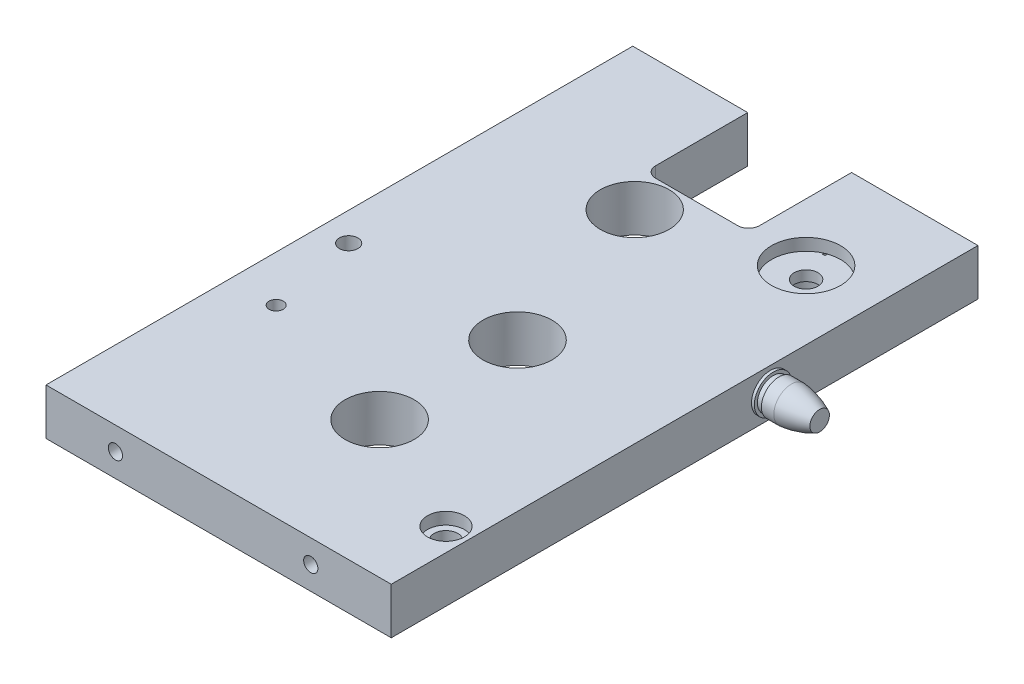
from build123d import *

# Parameters (mm, degrees)
SKETCH1_W           = 95.25
SKETCH1_H           = 12.8
BOSS_EXTRUDE1_DEPTH = 161.88
SKETCH1_3_R         = 3.1
CUT_EXTRUDE1_DEPTH  = 20.2
SKETCH1_4_R         = 2.395
CUT_EXTRUDE2_DEPTH  = 21.5
CUT_EXTRUDE3_REACH  = 369.677
SKETCH2_R           = 9.525
CUT_EXTRUDE4_REACH  = 369.677
SKETCH3_R           = 3.265
SKETCH3_R_2         = 1.96
SKETCH3_R_3         = 2.56
SKETCH4_R           = 9.525
SKETCH4_R_2         = 5.09
CUT_EXTRUDE5_DEPTH  = 3.32
SKETCH5_R           = 5.31
CUT_EXTRUDE6_DEPTH  = 6.65
SKETCH6_R           = 1.965
CUT_EXTRUDE7_DEPTH  = 17.25
SKETCH7_R           = 1.97
CUT_EXTRUDE8_DEPTH  = 15.87
SKETCH9_R           = 9.5
CUT_EXTRUDE9_DEPTH  = 368.677154617


with BuildPart() as part:
    # Sketch1 → Boss-Extrude1 (new body)
    with BuildSketch(Plane.XY):
        with Locations((-282.25, -616.5)):
            Rectangle(SKETCH1_W, SKETCH1_H)
    extrude(amount=BOSS_EXTRUDE1_DEPTH)

    # Sketch1_3 → Cut-Extrude1 (cut)
    with BuildSketch(Plane.XY):
        with Locations((-257, -616.5)):
            Circle(SKETCH1_3_R)
        with Locations((-307.5, -616.5)):
            Circle(SKETCH1_3_R)
    extrude(amount=CUT_EXTRUDE1_DEPTH, mode=Mode.SUBTRACT)

    # Sketch1_4 → Cut-Extrude2 (cut)
    with BuildSketch(Plane.XY):
        with Locations((-244.2, -616.5)):
            Circle(SKETCH1_4_R)
        with Locations((-320.5, -616.5)):
            Circle(SKETCH1_4_R)
    extrude(amount=CUT_EXTRUDE2_DEPTH, mode=Mode.SUBTRACT)

    # Sketch2 → Cut-Extrude3 (cut, up to next)
    with BuildSketch(Plane(origin=(0, -610.1, 0), x_dir=(1, 0, 0), z_dir=(0, 1, 0)), mode=Mode.PRIVATE) as cut_extrude3_sk1:
        with Locations((-275.57, -124.135)):
            Circle(SKETCH2_R)
    cut_extrude3_tool1 = extrude(cut_extrude3_sk1.sketch, amount=-CUT_EXTRUDE3_REACH, mode=Mode.PRIVATE) & part.part
    # Sketch2 → Cut-Extrude3 (cut, up to next)
    with BuildSketch(Plane(origin=(0, -610.1, 0), x_dir=(1, 0, 0), z_dir=(0, 1, 0)), mode=Mode.PRIVATE) as cut_extrude3_sk2:
        with Locations((-275.57, -86.105)):
            Circle(SKETCH2_R)
    cut_extrude3_tool2 = extrude(cut_extrude3_sk2.sketch, amount=-CUT_EXTRUDE3_REACH, mode=Mode.PRIVATE) & part.part
    # Sketch2 → Cut-Extrude3 (cut, up to next)
    with BuildSketch(Plane(origin=(0, -610.1, 0), x_dir=(1, 0, 0), z_dir=(0, 1, 0)), mode=Mode.PRIVATE) as cut_extrude3_sk3:
        with BuildLine():
            Line((-269.505, 0), (-298.155, 0))
            Line((-298.155, 0), (-298.155, -25.4))
            ThreePointArc((-298.155, -25.4), (-297.276320344, -27.521320344), (-295.155, -28.4))
            Line((-295.155, -28.4), (-272.505, -28.4))
            ThreePointArc((-272.505, -28.4), (-270.383679656, -27.521320344), (-269.505, -25.4))
            Line((-269.505, -25.4), (-269.505, 0))
        make_face()
    cut_extrude3_tool3 = extrude(cut_extrude3_sk3.sketch, amount=-CUT_EXTRUDE3_REACH, mode=Mode.PRIVATE) & part.part
    add(cut_extrude3_tool1.solids().sort_by_distance((-275.57, -610.1, 124.135))[0], mode=Mode.SUBTRACT)
    add(cut_extrude3_tool2.solids().sort_by_distance((-275.57, -610.1, 86.105))[0], mode=Mode.SUBTRACT)
    add(cut_extrude3_tool3.solids().sort_by_distance((-283.83, -610.1, 14.135461))[0], mode=Mode.SUBTRACT)

    # Sketch3 → Cut-Extrude4 (cut, up to next)
    with BuildSketch(Plane(origin=(0, -610.1, 0), x_dir=(-1, 0, 0), z_dir=(0, 1, 0)), mode=Mode.PRIVATE) as cut_extrude4_sk1:
        with Locations((240.925, 140.49)):
            Circle(SKETCH3_R)
    cut_extrude4_tool1 = extrude(cut_extrude4_sk1.sketch, amount=-CUT_EXTRUDE4_REACH, mode=Mode.PRIVATE) & part.part
    # Sketch3 → Cut-Extrude4 (cut, up to next)
    with BuildSketch(Plane(origin=(0, -610.1, 0), x_dir=(-1, 0, 0), z_dir=(0, 1, 0)), mode=Mode.PRIVATE) as cut_extrude4_sk2:
        with Locations((253.55, 28.505)):
            Circle(SKETCH3_R)
    cut_extrude4_tool2 = extrude(cut_extrude4_sk2.sketch, amount=-CUT_EXTRUDE4_REACH, mode=Mode.PRIVATE) & part.part
    # Sketch3 → Cut-Extrude4 (cut, up to next)
    with BuildSketch(Plane(origin=(0, -610.1, 0), x_dir=(-1, 0, 0), z_dir=(0, 1, 0)), mode=Mode.PRIVATE) as cut_extrude4_sk3:
        with Locations((317.175, 111.08)):
            Circle(SKETCH3_R_2)
    cut_extrude4_tool3 = extrude(cut_extrude4_sk3.sketch, amount=-CUT_EXTRUDE4_REACH, mode=Mode.PRIVATE) & part.part
    # Sketch3 → Cut-Extrude4 (cut, up to next)
    with BuildSketch(Plane(origin=(0, -610.1, 0), x_dir=(-1, 0, 0), z_dir=(0, 1, 0)), mode=Mode.PRIVATE) as cut_extrude4_sk4:
        with Locations((321.975, 86.28)):
            Circle(SKETCH3_R_3)
    cut_extrude4_tool4 = extrude(cut_extrude4_sk4.sketch, amount=-CUT_EXTRUDE4_REACH, mode=Mode.PRIVATE) & part.part
    add(cut_extrude4_tool1.solids().sort_by_distance((-240.925, -610.1, 140.49))[0], mode=Mode.SUBTRACT)
    add(cut_extrude4_tool2.solids().sort_by_distance((-253.55, -610.1, 28.505))[0], mode=Mode.SUBTRACT)
    add(cut_extrude4_tool3.solids().sort_by_distance((-317.175, -610.1, 111.08))[0], mode=Mode.SUBTRACT)
    add(cut_extrude4_tool4.solids().sort_by_distance((-321.975, -610.1, 86.28))[0], mode=Mode.SUBTRACT)

    # Sketch4 → Cut-Extrude5 (cut)
    with BuildSketch(Plane(origin=(0, -610.1, 0), x_dir=(-1, 0, 0), z_dir=(0, 1, 0))):
        with Locations((253.55, 28.505)):
            Circle(SKETCH4_R)
        with Locations((240.925, 140.49)):
            Circle(SKETCH4_R_2)
    extrude(amount=-CUT_EXTRUDE5_DEPTH, mode=Mode.SUBTRACT)

    # Sketch5 → Cut-Extrude6 (cut)
    with BuildSketch(Plane.XZ.offset(622.9)):
        with Locations((-240.925, 140.49)):
            Circle(SKETCH5_R)
        with Locations((-253.55, 28.505)):
            Circle(SKETCH5_R)
    extrude(amount=-CUT_EXTRUDE6_DEPTH, mode=Mode.SUBTRACT)

    # Sketch6 → Cut-Extrude7 (cut)
    with BuildSketch(Plane.XY.offset(161.88)):
        with Locations((-310.715, -616.48)):
            Circle(SKETCH6_R)
        with Locations((-256.825, -616.48)):
            Circle(SKETCH6_R)
    extrude(amount=-CUT_EXTRUDE7_DEPTH, mode=Mode.SUBTRACT)

    # Sketch7 → Cut-Extrude8 (cut)
    with BuildSketch(Plane.ZY.offset(329.875)):
        with Locations((142.28, -616.5)):
            Circle(SKETCH7_R)
    extrude(amount=-CUT_EXTRUDE8_DEPTH, mode=Mode.SUBTRACT)

    # Sketch8 → Revolve1 (revolve)
    with BuildSketch(Plane(origin=(0, -616.5, 0), x_dir=(-1, 0, 0), z_dir=(0, 1, 0))):
        with BuildLine():
            Line((234.625, 57.29), (221.025, 57.29))
            Line((221.025, 57.29), (221.025, 54.59))
            ThreePointArc((221.025, 54.59), (224.841543887, 53.18542762), (228.845807042, 52.475))
            Line((228.845807042, 52.475), (232.275807042, 52.475))
            Line((232.275807042, 52.475), (232.295, 52.925))
            Line((232.295, 52.925), (233.835, 52.925))
            Line((233.835, 52.925), (233.835, 52.09))
            Line((233.835, 52.09), (234.625, 52.09))
            Line((234.625, 52.09), (234.625, 57.29))
        make_face()
    revolve(axis=Axis((-234.625, -616.5, 57.29), (-1, 0, 0)))

    # Sketch9 → Cut-Extrude9 (cut, through all)
    with BuildSketch(Plane.XZ.offset(622.9)):
        with Locations((-290.57, 38.77)):
            Circle(SKETCH9_R)
    extrude(amount=-CUT_EXTRUDE9_DEPTH, mode=Mode.SUBTRACT)


solid = part.part
